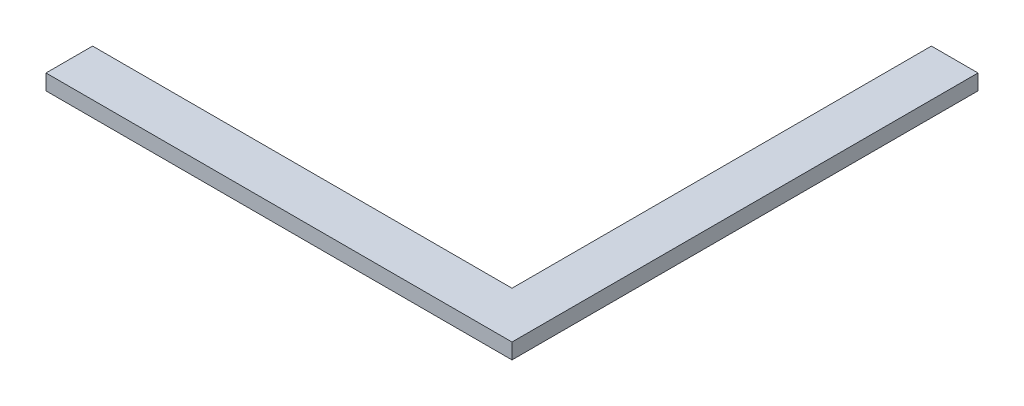
from build123d import *

# Parameters (mm, degrees)
BOSS_EXTRUDE1_DEPTH = 10


with BuildPart() as part:
    # Sketch1 → Boss-Extrude1 (new body)
    with BuildSketch(Plane(origin=(0, 0, 0), x_dir=(1, 0, 0), z_dir=(0, 1, 0))):
        Polygon((-150, -150), (150, -150), (150, 150), (120, 150), (120, -120), (-150, -120), align=None)
    extrude(amount=BOSS_EXTRUDE1_DEPTH)


solid = part.part
